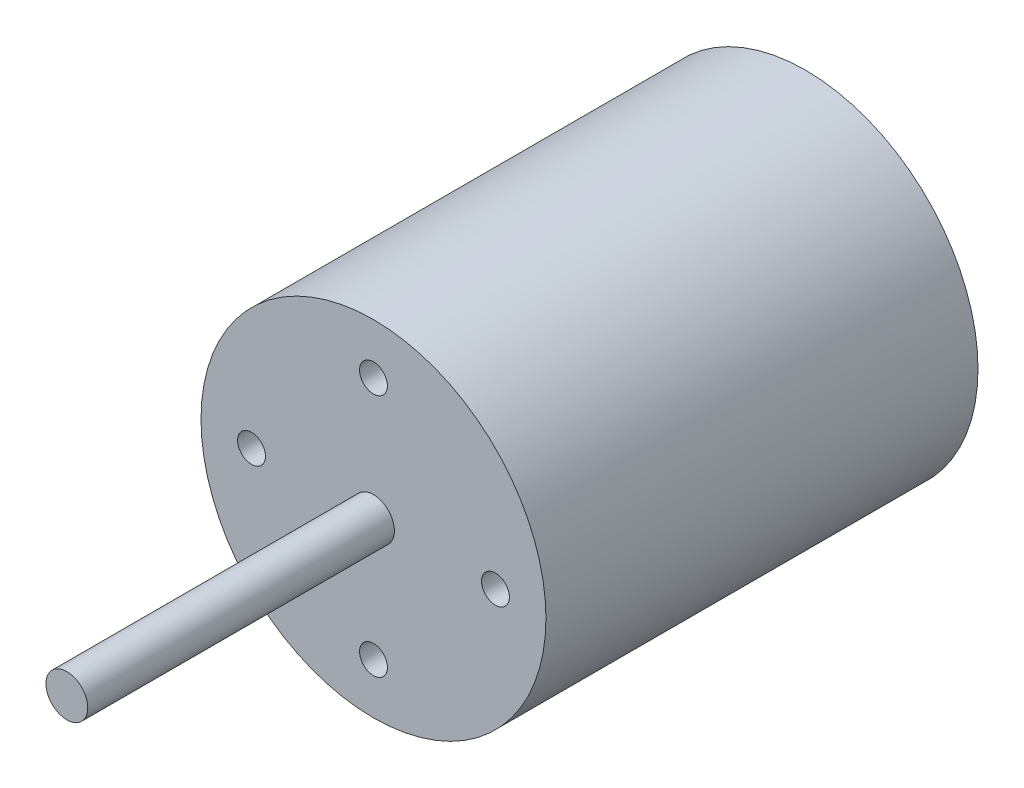
from build123d import *

# Parameters (mm, degrees)
SKETCH1_R           = 24.75
BOSS_EXTRUDE1_DEPTH = 31
SKETCH2_R           = 3
BOSS_EXTRUDE2_DEPTH = 44
SKETCH6_R           = 2
CUT_EXTRUDE3_DEPTH  = 5
CIRPATTERN1_COUNT   = 4
SKETCH5_R           = 2
CUT_EXTRUDE2_DEPTH  = 10
CIRPATTERN2_COUNT   = 2
SKETCH7_R           = 9
BOSS_EXTRUDE3_DEPTH = 7


with BuildPart() as part:
    # Sketch1 → Boss-Extrude1 (new body, symmetric)
    with BuildSketch(Plane.XY):
        Circle(SKETCH1_R)
    extrude(amount=BOSS_EXTRUDE1_DEPTH, both=True)

    # Sketch2 → Boss-Extrude2 (add)
    with BuildSketch(Plane.XY.offset(31)):
        Circle(SKETCH2_R)
    extrude(amount=BOSS_EXTRUDE2_DEPTH)

    # Sketch6 → Cut-Extrude3 (cut)
    with BuildSketch(Plane.XY.offset(31)):
        with Locations((0, 17.5)):
            Circle(SKETCH6_R)
    cut_extrude3 = extrude(amount=-CUT_EXTRUDE3_DEPTH, mode=Mode.SUBTRACT)

    # CirPattern1: Cut-Extrude3 ×4 about axis
    cirpattern1_axis = Axis((0, 0, 0), (0, 0, 1))
    for i in range(1, CIRPATTERN1_COUNT):
        add(cut_extrude3.rotate(cirpattern1_axis, i * 360 / CIRPATTERN1_COUNT), mode=Mode.SUBTRACT)

    # Sketch5 → Cut-Extrude2 (cut)
    with BuildSketch(Plane(origin=(0, 0, -31), x_dir=(-1, 0, 0), z_dir=(0, 0, -1))):
        with Locations((-17.5, 0)):
            Circle(SKETCH5_R)
    cut_extrude2 = extrude(amount=-CUT_EXTRUDE2_DEPTH, mode=Mode.SUBTRACT)

    # CirPattern2: Cut-Extrude2 ×2 about axis
    cirpattern2_axis = Axis((0, 0, 0), (0, 0, 1))
    for i in range(1, CIRPATTERN2_COUNT):
        add(cut_extrude2.rotate(cirpattern2_axis, i * 360 / CIRPATTERN2_COUNT), mode=Mode.SUBTRACT)

    # Sketch7 → Boss-Extrude3 (add)
    with BuildSketch(Plane(origin=(0, 0, -31), x_dir=(-1, 0, 0), z_dir=(0, 0, -1))):
        Circle(SKETCH7_R)
    extrude(amount=BOSS_EXTRUDE3_DEPTH)


solid = part.part
